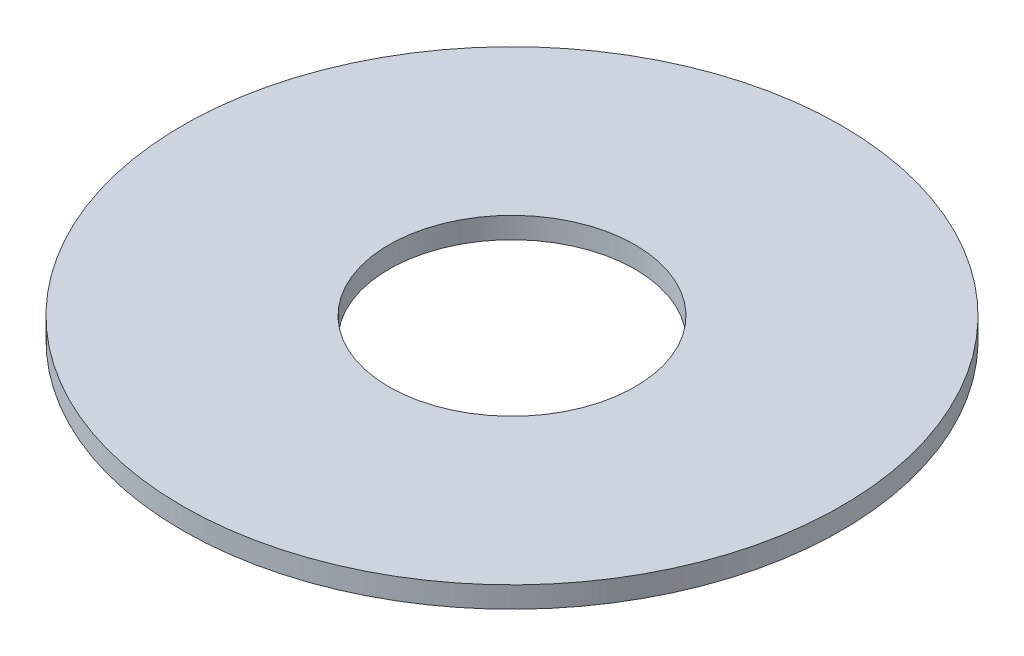
from build123d import *

# Parameters (mm, degrees)
SKETCH1_R           = 11.0871
SKETCH1_R_2         = 4.1402
BOSS_EXTRUDE1_DEPTH = 0.7112


with BuildPart() as part:
    # Sketch1 → Boss-Extrude1 (new body)
    with BuildSketch(Plane(origin=(0, 0, 0), x_dir=(1, 0, 0), z_dir=(0, 1, 0))):
        Circle(SKETCH1_R)
        Circle(SKETCH1_R_2, mode=Mode.SUBTRACT)
    extrude(amount=BOSS_EXTRUDE1_DEPTH)


solid = part.part
